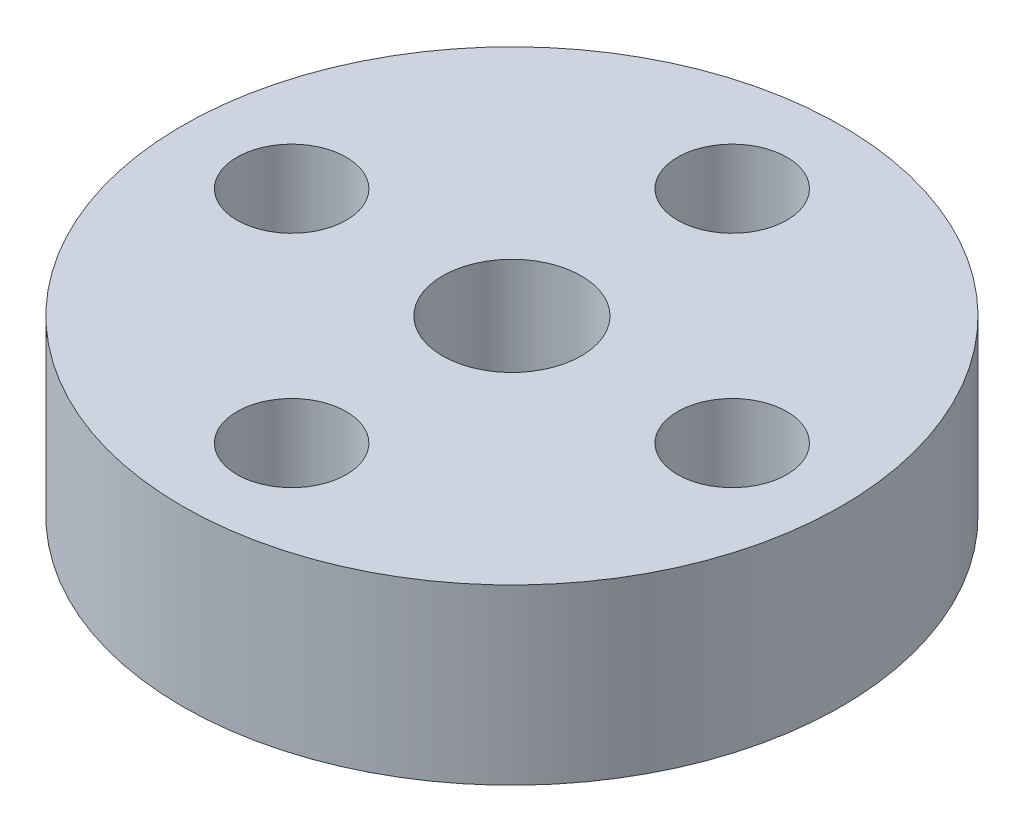
from build123d import *

# Parameters (mm, degrees)
SKETCH1_R           = 9.5
BOSS_EXTRUDE1_DEPTH = 5
SKETCH2_R           = 1.575
SKETCH2_R_2         = 2
CUT_EXTRUDE1_DEPTH  = 5


with BuildPart() as part:
    # Sketch1 → Boss-Extrude1 (new body)
    with BuildSketch(Plane(origin=(0, 0, 0), x_dir=(1, 0, 0), z_dir=(0, 1, 0))):
        Circle(SKETCH1_R)
    extrude(amount=BOSS_EXTRUDE1_DEPTH)

    # Sketch2 → Cut-Extrude1 (cut)
    with BuildSketch(Plane(origin=(0, 5, 0), x_dir=(1, 0, 0), z_dir=(0, 1, 0))):
        with Locations((0, 6.35)):
            Circle(SKETCH2_R)
        with Locations((6.35, 0)):
            Circle(SKETCH2_R)
        with Locations((0, -6.35)):
            Circle(SKETCH2_R)
        with Locations((-6.35, 0)):
            Circle(SKETCH2_R)
        Circle(SKETCH2_R_2)
    extrude(amount=-CUT_EXTRUDE1_DEPTH, mode=Mode.SUBTRACT)


solid = part.part
